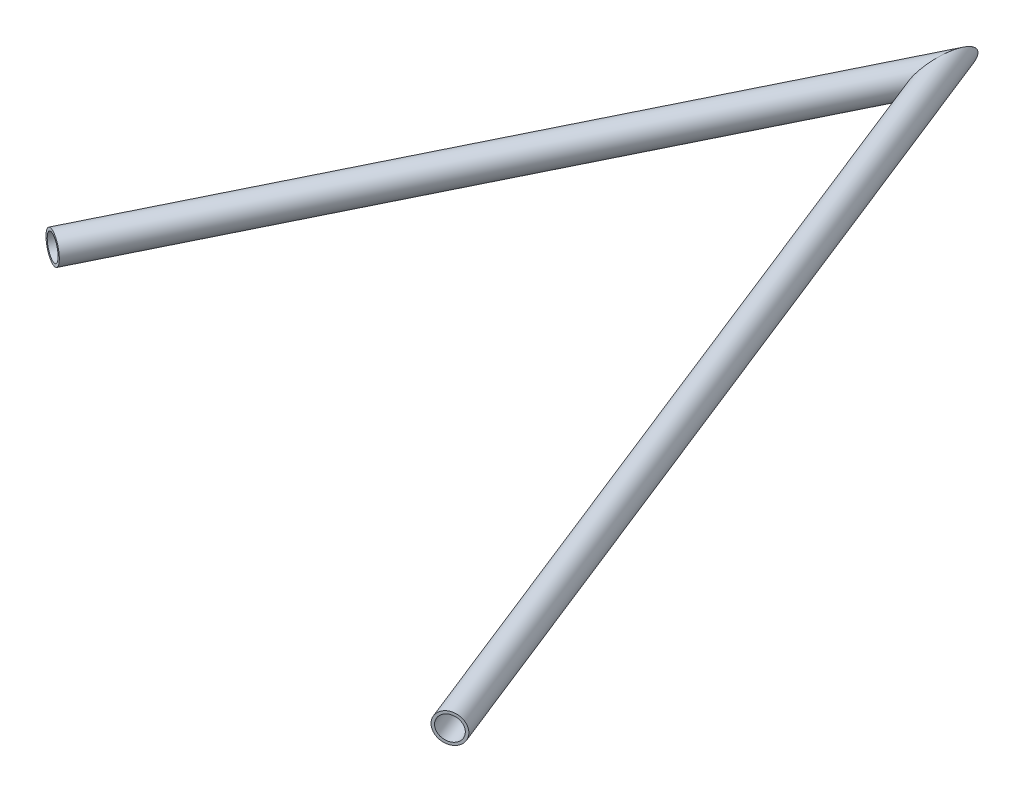
from build123d import *

# Parameters (mm, degrees)
SKETCH11_ON_SEGMENT_1_R         = 7.9375
SKETCH11_ON_SEGMENT_1_R_2       = 6.4643
STRUCTURAL_MEMBER1_DEPTH        = 502.870881135
SKETCH11_R                      = 7.9375
SKETCH11_R_2                    = 6.4643
STRUCTURAL_MEMBER1_2_DEPTH      = 361.438445442
STRUCTURAL_MEMBER1_2_DEPTH_BACK = 26.330451864


with BuildPart() as part:
    # Sketch11 on segment 1 (carried to segment 1) → Structural Member1 (new body)
    with BuildSketch(Plane(origin=(175.642001203, 0, 442.990595998), x_dir=(-0.929597089, 0, 0.368577335), z_dir=(-0.368577335, 0, -0.929597089))):
        Circle(SKETCH11_ON_SEGMENT_1_R)
        Circle(SKETCH11_ON_SEGMENT_1_R_2, mode=Mode.SUBTRACT)
    extrude(amount=STRUCTURAL_MEMBER1_DEPTH)

    # Structural Member1 mitre 1
    split(bisect_by=Plane(origin=(0, 0, 0), x_dir=(0, 1, 0), z_dir=(0.999213287, 0, 0.039658638)), keep=Keep.TOP)


with BuildPart() as body_2:
    # Sketch11 → Structural Member1 2 (new, two sides)
    with BuildSketch(Plane(origin=(0, 0, 0), x_dir=(0.8974613837581003, 0, 0.4410930340222977), z_dir=(-0.4410930340222977, 0, 0.8974613837581003))) as structural_member1_2_sk:
        Circle(SKETCH11_R)
        Circle(SKETCH11_R_2, mode=Mode.SUBTRACT)
    extrude(amount=STRUCTURAL_MEMBER1_2_DEPTH)
    extrude(structural_member1_2_sk.sketch, amount=-STRUCTURAL_MEMBER1_2_DEPTH_BACK)

    # Structural Member1 2 mitre 1
    split(bisect_by=Plane(origin=(0, 0, 0), x_dir=(0, -1, 0), z_dir=(-0.999213287, 0, -0.039658638)), keep=Keep.TOP)


solid = Compound([part.part, body_2.part])
